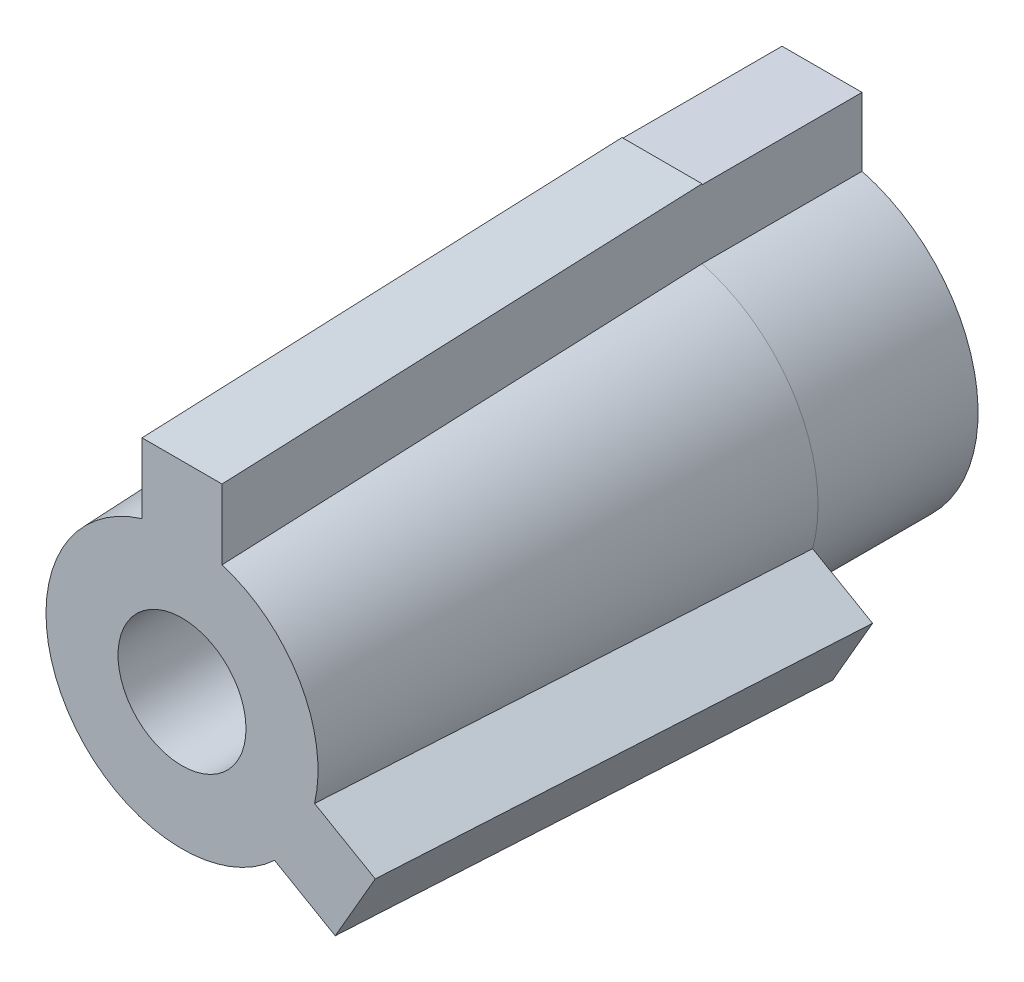
from build123d import *

# Parameters (mm, degrees)
SKETCH1_R           = 8.5
SKETCH1_R_2         = 4
BOSS_EXTRUDE1_DEPTH = 30
SKETCH2_R           = 9.75
BOSS_EXTRUDE2_DEPTH = 10
SKETCH4_R           = 4
CUT_EXTRUDE1_DEPTH  = 40
SKETCH6_W           = 5
SKETCH6_H           = 6.142281657
SKETCH5_W           = 5
SKETCH5_H           = 5.134988922
CIRPATTERN1_COUNT   = 2
CIRPATTERN1_ANGLE   = 240
SKETCH7_W           = 5
SKETCH7_H           = 5.55011225
BOSS_EXTRUDE3_DEPTH = 10


with BuildPart() as part:
    # Sketch1 → Boss-Extrude1 (new body)
    with BuildSketch(Plane.XY):
        Circle(SKETCH1_R)
        Circle(SKETCH1_R_2, mode=Mode.SUBTRACT)
    extrude(amount=BOSS_EXTRUDE1_DEPTH)

    # Sketch2 → Boss-Extrude2 (add)
    with BuildSketch(Plane(origin=(0, 0, 0), x_dir=(-1, 0, 0), z_dir=(0, 0, -1))):
        Circle(SKETCH2_R)
    extrude(amount=BOSS_EXTRUDE2_DEPTH)

    # loft up to a face of the part (loft4)
    loft([Face(Wire([part.edges().sort_by_distance((-5.8186504, 6.196233333, 30))[0]])), Face(Wire([part.edges().sort_by_distance((6.674334283, -7.107444117, 0))[0]]))])

    # Sketch4 → Cut-Extrude1 (cut)
    with BuildSketch(Plane.XY.offset(30)):
        Circle(SKETCH4_R)
    extrude(amount=-CUT_EXTRUDE1_DEPTH, mode=Mode.SUBTRACT)

    # Sketch6 → Loft5 section 0
    with BuildSketch(Plane.XY.offset(30)):
        with Locations((0, 9.428859172)):
            Rectangle(SKETCH6_W, SKETCH6_H)
    # Sketch5 → Loft5 section 1
    with BuildSketch(Plane.XY):
        with Locations((0, 11.182505539)):
            Rectangle(SKETCH5_W, SKETCH5_H)
    loft5 = loft()

    # CirPattern1: Loft5 ×2 about axis
    cirpattern1_axis = Axis((0, 0, 0), (0, 0, 1))
    for i in range(1, CIRPATTERN1_COUNT):
        add(loft5.rotate(cirpattern1_axis, i * CIRPATTERN1_ANGLE / (CIRPATTERN1_COUNT - 1)))

    # Sketch7 → Boss-Extrude3 (add)
    with BuildSketch(Plane(origin=(0, 0, -10), x_dir=(-1, 0, 0), z_dir=(0, 0, -1))):
        with Locations((0, 10.919421432)):
            Rectangle(SKETCH7_W, SKETCH7_H)
    extrude(amount=-BOSS_EXTRUDE3_DEPTH)


solid = part.part
